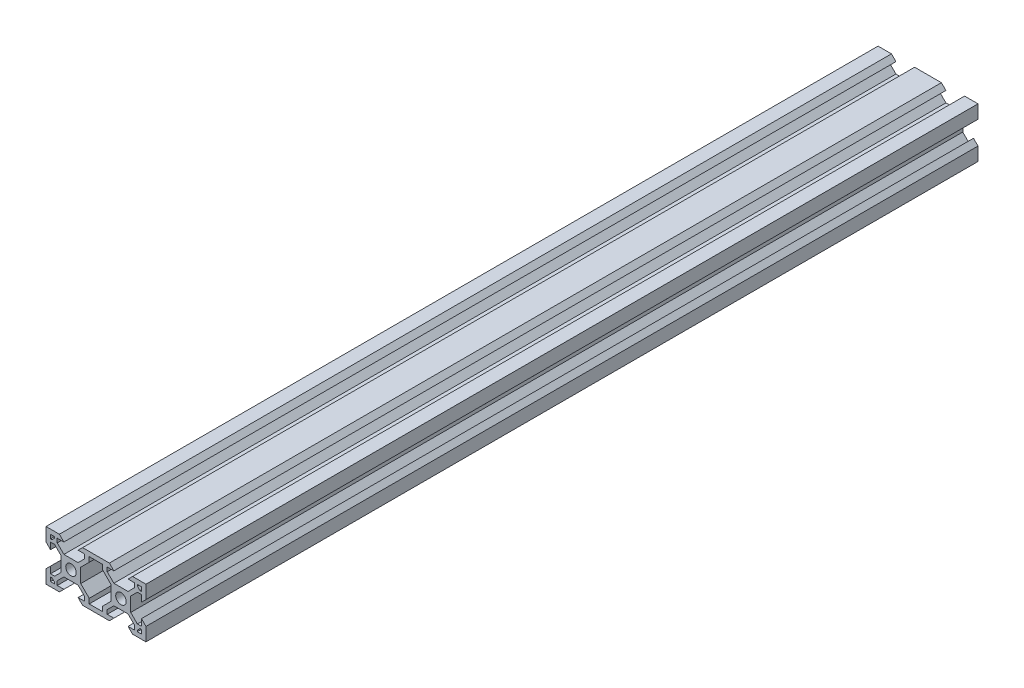
from build123d import *

# Parameters (mm, degrees)
SKETCH1_R           = 2.1
BOSS_EXTRUDE1_DEPTH = 333


with BuildPart() as part:
    # Sketch1 → Boss-Extrude1 (new body)
    with BuildSketch(Plane.XY):
        Polygon((0, 0), (0, 5.36), (1.8, 7.16), (1.8, 4.500660172), (3.44, 4.500660172), (6.099339828, 7.16), (6.099339828, 12.84), (3.44, 15.499339828), (1.8, 15.499339828), (1.8, 12.84), (0, 14.64), (0, 20), (5.36, 20), (7.16, 18.2), (4.500660172, 18.2), (4.500660172, 16.56), (7.16, 13.900660172), (12.84, 13.900660172), (15.499339828, 16.56), (15.499339828, 18.2), (12.84, 18.2), (14.64, 20), (20, 20), (25.36, 20), (27.16, 18.2), (24.500939946, 18.2), (24.50125838, 16.559689577), (27.161114417, 13.900866058), (32.84111431, 13.901968719), (35.499937829, 16.561824756), (35.49961981, 18.2), (32.84, 18.2), (34.64, 20), (39.999930631, 20), (40.000970647, 14.642698508), (38.201320116, 12.842349107), (38.200803857, 15.501688885), (36.560803888, 15.501370511), (33.901980368, 12.841514474), (33.903083029, 7.161514581), (36.562939066, 4.502691062), (38.202939036, 4.503009436), (38.202422777, 7.162349214), (40.002772178, 5.362698683), (40.003813241, 0), (34.64, 0), (32.84, 1.8), (35.502803549, 1.8), (35.502484821, 3.441825004), (32.842628784, 6.100648523), (27.162628891, 6.099545862), (24.503805372, 3.439689825), (24.504123686, 1.8), (27.16, 1.8), (25.36, 0), (20, 0), (14.64, 0), (12.84, 1.8), (15.499339828, 1.8), (15.499339828, 3.44), (12.84, 6.099339828), (7.16, 6.099339828), (4.500660172, 3.44), (4.500660172, 1.8), (7.16, 1.8), (5.36, 0), align=None)
        with Locations((10, 10)):
            Circle(SKETCH1_R, mode=Mode.SUBTRACT)
        with Locations((30, 10)):
            Circle(SKETCH1_R, mode=Mode.SUBTRACT)
        Polygon((17.300660172, 3.76), (17.300660172, 1.8), (22.700660172, 1.8), (22.700660172, 3.76), (26.100660172, 7.16), (26.100660172, 12.84), (22.699339828, 16.24), (22.699339828, 18.2), (17.300660172, 18.2), (17.300660172, 16.24), (13.900660172, 12.84), (13.900660172, 7.16), align=None, mode=Mode.SUBTRACT)
        Polygon((1.8, 18.2), (3.430660172, 18.2), (3.430660172, 17.63), (2.37, 16.569339828), (1.8, 16.569339828), align=None, mode=Mode.SUBTRACT)
        Polygon((1.8, 3.430660172), (1.8, 1.8), (3.430660172, 1.8), (3.430660172, 2.37), (2.37, 3.430660172), align=None, mode=Mode.SUBTRACT)
        Polygon((38.2, 1.8), (36.569339828, 1.8), (36.569339828, 2.37), (37.63, 3.430660172), (38.2, 3.430660172), align=None, mode=Mode.SUBTRACT)
        Polygon((38.2, 16.569339828), (38.2, 18.2), (36.569339828, 18.2), (36.569339828, 17.63), (37.63, 16.569339828), align=None, mode=Mode.SUBTRACT)
    extrude(amount=-BOSS_EXTRUDE1_DEPTH)


solid = part.part
